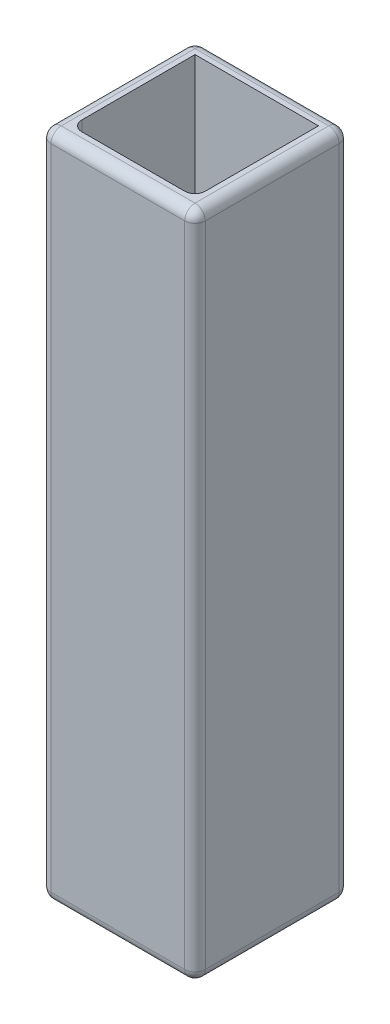
from build123d import *

# Parameters (mm, degrees)
CROQUIS1_W              = 30
CROQUIS1_H              = 30
CROQUIS1_W_2            = 24
CROQUIS1_H_2            = 24
SALIENTE_EXTRUIR1_DEPTH = 130
REDONDEO2_R             = 2


with BuildPart() as part:
    # Croquis1 → Saliente-Extruir1 (new body)
    with BuildSketch(Plane(origin=(0, 0, 0), x_dir=(1, 0, 0), z_dir=(0, 1, 0))):
        Rectangle(CROQUIS1_W, CROQUIS1_H)
        Rectangle(CROQUIS1_W_2, CROQUIS1_H_2, mode=Mode.SUBTRACT)
    extrude(amount=SALIENTE_EXTRUIR1_DEPTH)

    # Redondeo2
    redondeo2_edges = [part.edges().sort_by_distance(p)[0] for p in [
        (-15, 130, 0),
        (0, 130, 15),
        (12, 65, 12),
        (-12, 65, 12),
        (15, 130, 0),
        (0, 0, 15),
        (-15, 0, 0),
        (0, 0, -15),
        (15, 0, 0),
        (0, 130, -15),
        (15, 65, 15),
        (-15, 65, 15),
        (-15, 65, -15),
        (15, 65, -15),
    ]]
    fillet(redondeo2_edges, radius=REDONDEO2_R)


solid = part.part
